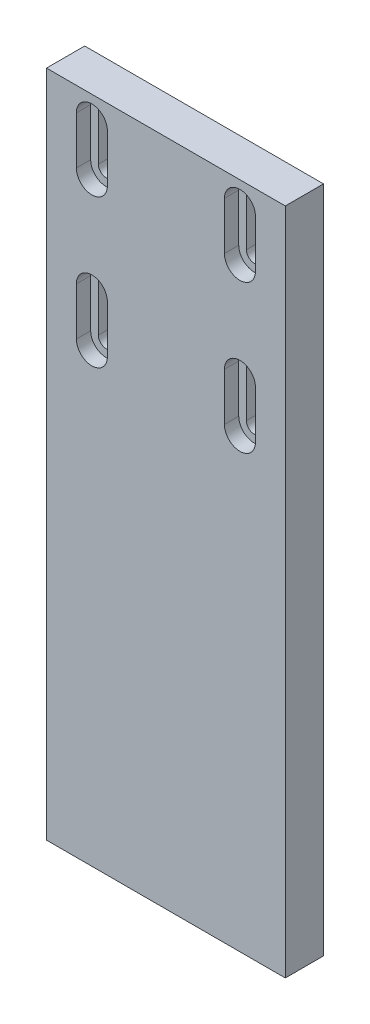
from build123d import *

# Parameters (mm, degrees)
SKETCH_1_W          = 50
SKETCH_1_H          = 140
EXTRUDE_1_DEPTH     = 8
CUT_EXTRUDE_2_DEPTH = 8
CUT_EXTRUDE_3_DEPTH = 3


with BuildPart() as part:
    # 草圖1 → 填料-伸長1 (new body)
    with BuildSketch(Plane.XY):
        Rectangle(SKETCH_1_W, SKETCH_1_H)
    extrude(amount=EXTRUDE_1_DEPTH)

    # 草圖8 → 除料-伸長2 (cut)
    with BuildSketch(Plane.XY.offset(8)):
        with BuildLine():
            Line((-13.85, 65), (-13.85, 55))
            ThreePointArc((-13.85, 55), (-15.5, 53.35), (-17.15, 55))
            Line((-17.15, 55), (-17.15, 65))
            ThreePointArc((-17.15, 65), (-15.5, 66.65), (-13.85, 65))
        make_face()
        with BuildLine():
            Line((13.85, 65), (13.85, 55))
            ThreePointArc((13.85, 55), (15.5, 53.35), (17.15, 55))
            Line((17.15, 55), (17.15, 65))
            ThreePointArc((17.15, 65), (15.5, 66.65), (13.85, 65))
        make_face()
        with BuildLine():
            Line((13.85, 34), (13.85, 24))
            ThreePointArc((13.85, 24), (15.5, 22.35), (17.15, 24))
            Line((17.15, 24), (17.15, 34))
            ThreePointArc((17.15, 34), (15.5, 35.65), (13.85, 34))
        make_face()
        with BuildLine():
            Line((-17.15, 34), (-17.15, 24))
            ThreePointArc((-17.15, 24), (-15.5, 22.35), (-13.85, 24))
            Line((-13.85, 24), (-13.85, 34))
            ThreePointArc((-13.85, 34), (-15.5, 35.65), (-17.15, 34))
        make_face()
    extrude(amount=-CUT_EXTRUDE_2_DEPTH, mode=Mode.SUBTRACT)

    # 草圖9 → 除料-伸長3 (cut)
    with BuildSketch(Plane.XY.offset(8)):
        with BuildLine():
            Line((-12.25, 65), (-12.25, 55))
            ThreePointArc((-12.25, 55), (-15.5, 51.75), (-18.75, 55))
            Line((-18.75, 55), (-18.75, 65))
            ThreePointArc((-18.75, 65), (-15.5, 68.25), (-12.25, 65))
        make_face()
        with BuildLine():
            Line((12.25, 65), (12.25, 55))
            ThreePointArc((12.25, 55), (15.5, 51.75), (18.75, 55))
            Line((18.75, 55), (18.75, 65))
            ThreePointArc((18.75, 65), (15.5, 68.25), (12.25, 65))
        make_face()
        with BuildLine():
            Line((12.25, 34), (12.25, 24))
            ThreePointArc((12.25, 24), (15.5, 20.75), (18.75, 24))
            Line((18.75, 24), (18.75, 34))
            ThreePointArc((18.75, 34), (15.5, 37.25), (12.25, 34))
        make_face()
        with BuildLine():
            Line((-18.75, 34), (-18.75, 24))
            ThreePointArc((-18.75, 24), (-15.5, 20.75), (-12.25, 24))
            Line((-12.25, 24), (-12.25, 34))
            ThreePointArc((-12.25, 34), (-15.5, 37.25), (-18.75, 34))
        make_face()
    extrude(amount=-CUT_EXTRUDE_3_DEPTH, mode=Mode.SUBTRACT)


solid = part.part
